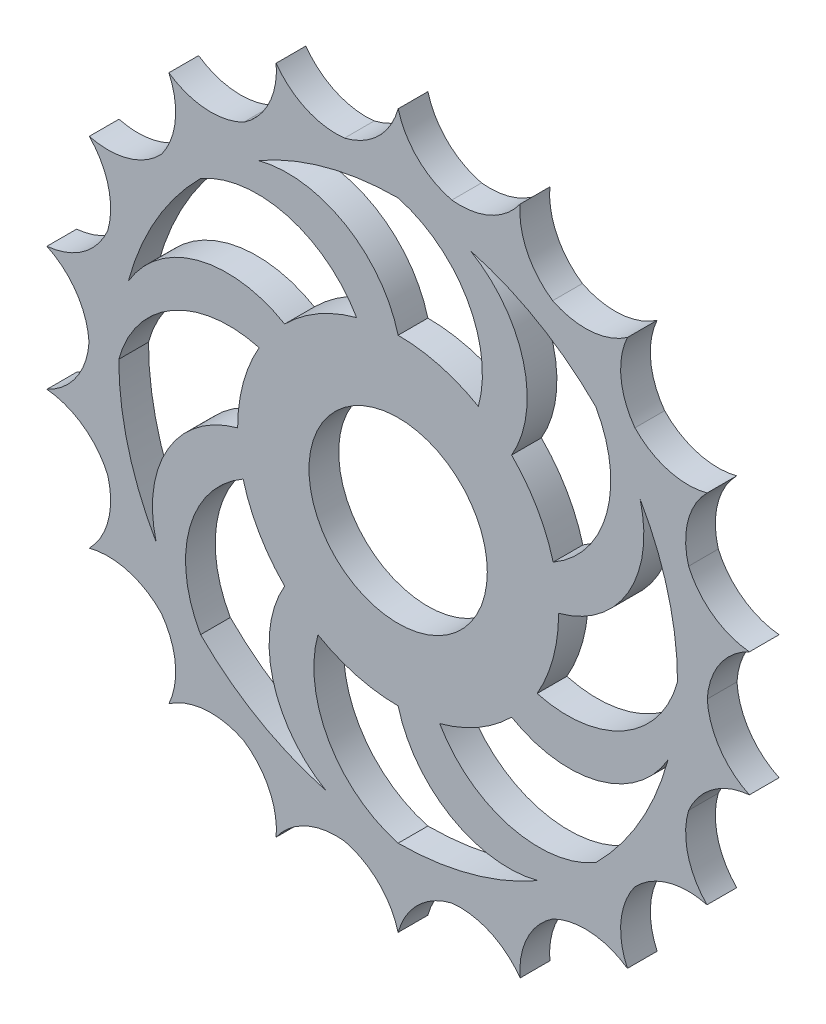
from build123d import *

# Parameters (mm, degrees)
SALIENTE_EXTRUIR1_DEPTH = 1.5875
CROQUIS2_R              = 9.525
CORTAR_EXTRUIR1_DEPTH   = 54.567986966


with BuildPart() as part:
    # Croquis1 → Saliente-Extruir1 (new, symmetric)
    with BuildSketch(Plane.XY):
        with BuildLine():
            ThreePointArc((37.52117539, -6.615995569), (34.367507804, -3.922405841), (33.02, 0))
            ThreePointArc((33.02, 0), (34.367507804, 3.922405841), (37.52117539, 6.615995569))
            ThreePointArc((37.52117539, 6.615995569), (33.636435286, 8.06852412), (31.028650338, 11.293505133))
            ThreePointArc((31.028650338, 11.293505133), (30.95335167, 15.440235769), (32.995567884, 19.05))
            ThreePointArc((32.995567884, 19.05), (28.848312252, 19.086270994), (25.294787512, 21.224846872))
            ThreePointArc((25.294787512, 21.224846872), (23.805764502, 25.09574539), (24.490207929, 29.186293283))
            ThreePointArc((24.490207929, 29.186293283), (20.580657004, 27.801931903), (16.51, 28.596158833))
            ThreePointArc((16.51, 28.596158833), (13.7868508, 31.724337744), (13.030967461, 35.802288852))
            ThreePointArc((13.030967461, 35.802288852), (9.830670784, 33.164269511), (5.733862827, 32.518352004))
            ThreePointArc((5.733862827, 32.518352004), (2.105039418, 34.526506764), (0, 38.1))
            ThreePointArc((0, 38.1), (-2.105039418, 34.526506764), (-5.733862827, 32.518352004))
            ThreePointArc((-5.733862827, 32.518352004), (-9.830670784, 33.164269511), (-13.030967461, 35.802288852))
            ThreePointArc((-13.030967461, 35.802288852), (-13.7868508, 31.724337744), (-16.51, 28.596158833))
            ThreePointArc((-16.51, 28.596158833), (-20.580657004, 27.801931903), (-24.490207929, 29.186293283))
            ThreePointArc((-24.490207929, 29.186293283), (-23.805764502, 25.09574539), (-25.294787512, 21.224846872))
            ThreePointArc((-25.294787512, 21.224846872), (-28.848312252, 19.086270994), (-32.995567884, 19.05))
            ThreePointArc((-32.995567884, 19.05), (-30.95335167, 15.440235769), (-31.028650338, 11.293505133))
            ThreePointArc((-31.028650338, 11.293505133), (-33.636435286, 8.06852412), (-37.52117539, 6.615995569))
            ThreePointArc((-37.52117539, 6.615995569), (-34.367507804, 3.922405841), (-33.02, 0))
            ThreePointArc((-33.02, 0), (-34.367507804, -3.922405841), (-37.52117539, -6.615995569))
            ThreePointArc((-37.52117539, -6.615995569), (-33.636435286, -8.06852412), (-31.028650338, -11.293505133))
            ThreePointArc((-31.028650338, -11.293505133), (-30.95335167, -15.440235769), (-32.995567884, -19.05))
            ThreePointArc((-32.995567884, -19.05), (-28.848312252, -19.086270994), (-25.294787512, -21.224846872))
            ThreePointArc((-25.294787512, -21.224846872), (-23.805764502, -25.09574539), (-24.490207929, -29.186293283))
            ThreePointArc((-24.490207929, -29.186293283), (-20.580657004, -27.801931903), (-16.51, -28.596158833))
            ThreePointArc((-16.51, -28.596158833), (-13.7868508, -31.724337744), (-13.030967461, -35.802288852))
            ThreePointArc((-13.030967461, -35.802288852), (-9.830670784, -33.164269511), (-5.733862827, -32.518352004))
            ThreePointArc((-5.733862827, -32.518352004), (-2.105039418, -34.526506764), (0, -38.1))
            ThreePointArc((0, -38.1), (2.105039418, -34.526506764), (5.733862827, -32.518352004))
            ThreePointArc((5.733862827, -32.518352004), (9.830670784, -33.164269511), (13.030967461, -35.802288852))
            ThreePointArc((13.030967461, -35.802288852), (13.7868508, -31.724337744), (16.51, -28.596158833))
            ThreePointArc((16.51, -28.596158833), (20.580657004, -27.801931903), (24.490207929, -29.186293283))
            ThreePointArc((24.490207929, -29.186293283), (23.805764502, -25.09574539), (25.294787512, -21.224846872))
            ThreePointArc((25.294787512, -21.224846872), (28.848312252, -19.086270994), (32.995567884, -19.05))
            ThreePointArc((32.995567884, -19.05), (30.95335167, -15.440235769), (31.028650338, -11.293505133))
            ThreePointArc((31.028650338, -11.293505133), (33.636435286, -8.06852412), (37.52117539, -6.615995569))
        make_face()
    extrude(amount=SALIENTE_EXTRUIR1_DEPTH, both=True)

    # Croquis2 → Cortar-Extruir1 (cut, through all)
    with BuildSketch(Plane.XY.offset(1.5875)):
        Circle(CROQUIS2_R)
        with BuildLine():
            ThreePointArc((8.5725, 14.848005548), (4.437452528, 16.560798292), (0, 17.145))
            ThreePointArc((0, 17.145), (-5.659104508, 24.58631503), (-14.9225, 25.846528176))
            ThreePointArc((-14.9225, 25.846528176), (-7.724454401, 28.828056286), (0, 29.845))
            ThreePointArc((0, 29.845), (7.392229248, 24.121925656), (8.5725, 14.848005548))
        make_face()
        with BuildLine():
            ThreePointArc((21.103601885, 21.103601885), (14.9225, 25.846528176), (7.724454401, 28.828056286))
            ThreePointArc((7.724454401, 28.828056286), (13.383558909, 21.386741255), (12.123345763, 12.123345763))
            ThreePointArc((12.123345763, 12.123345763), (14.848005548, 8.5725), (16.560798292, 4.437452528))
            ThreePointArc((16.560798292, 4.437452528), (22.283872636, 11.829681777), (21.103601885, 21.103601885))
        make_face()
        with BuildLine():
            ThreePointArc((29.845, 0), (28.828056286, 7.724454401), (25.846528176, 14.9225))
            ThreePointArc((25.846528176, 14.9225), (24.58631503, 5.659104508), (17.145, 0))
            ThreePointArc((17.145, 0), (16.560798292, -4.437452528), (14.848005548, -8.5725))
            ThreePointArc((14.848005548, -8.5725), (24.121925656, -7.392229248), (29.845, 0))
        make_face()
        with BuildLine():
            ThreePointArc((21.103601885, -21.103601885), (25.846528176, -14.9225), (28.828056286, -7.724454401))
            ThreePointArc((28.828056286, -7.724454401), (21.386741255, -13.383558909), (12.123345763, -12.123345763))
            ThreePointArc((12.123345763, -12.123345763), (8.5725, -14.848005548), (4.437452528, -16.560798292))
            ThreePointArc((4.437452528, -16.560798292), (11.829681777, -22.283872636), (21.103601885, -21.103601885))
        make_face()
        with BuildLine():
            ThreePointArc((0, -29.845), (7.724454401, -28.828056286), (14.9225, -25.846528176))
            ThreePointArc((14.9225, -25.846528176), (5.659104508, -24.58631503), (0, -17.145))
            ThreePointArc((0, -17.145), (-4.437452528, -16.560798292), (-8.5725, -14.848005548))
            ThreePointArc((-8.5725, -14.848005548), (-7.392229248, -24.121925656), (0, -29.845))
        make_face()
        with BuildLine():
            ThreePointArc((-21.103601885, -21.103601885), (-14.9225, -25.846528176), (-7.724454401, -28.828056286))
            ThreePointArc((-7.724454401, -28.828056286), (-13.383558909, -21.386741255), (-12.123345763, -12.123345763))
            ThreePointArc((-12.123345763, -12.123345763), (-14.848005548, -8.5725), (-16.560798292, -4.437452528))
            ThreePointArc((-16.560798292, -4.437452528), (-22.283872636, -11.829681777), (-21.103601885, -21.103601885))
        make_face()
        with BuildLine():
            ThreePointArc((-29.845, 0), (-28.828056286, -7.724454401), (-25.846528176, -14.9225))
            ThreePointArc((-25.846528176, -14.9225), (-24.58631503, -5.659104508), (-17.145, 0))
            ThreePointArc((-17.145, 0), (-16.560798292, 4.437452528), (-14.848005548, 8.5725))
            ThreePointArc((-14.848005548, 8.5725), (-24.121925656, 7.392229248), (-29.845, 0))
        make_face()
        with BuildLine():
            ThreePointArc((-21.103601885, 21.103601885), (-25.846528176, 14.9225), (-28.828056286, 7.724454401))
            ThreePointArc((-28.828056286, 7.724454401), (-21.386741255, 13.383558909), (-12.123345763, 12.123345763))
            ThreePointArc((-12.123345763, 12.123345763), (-8.5725, 14.848005548), (-4.437452528, 16.560798292))
            ThreePointArc((-4.437452528, 16.560798292), (-11.829681777, 22.283872636), (-21.103601885, 21.103601885))
        make_face()
    extrude(amount=-CORTAR_EXTRUIR1_DEPTH, mode=Mode.SUBTRACT)


solid = part.part
